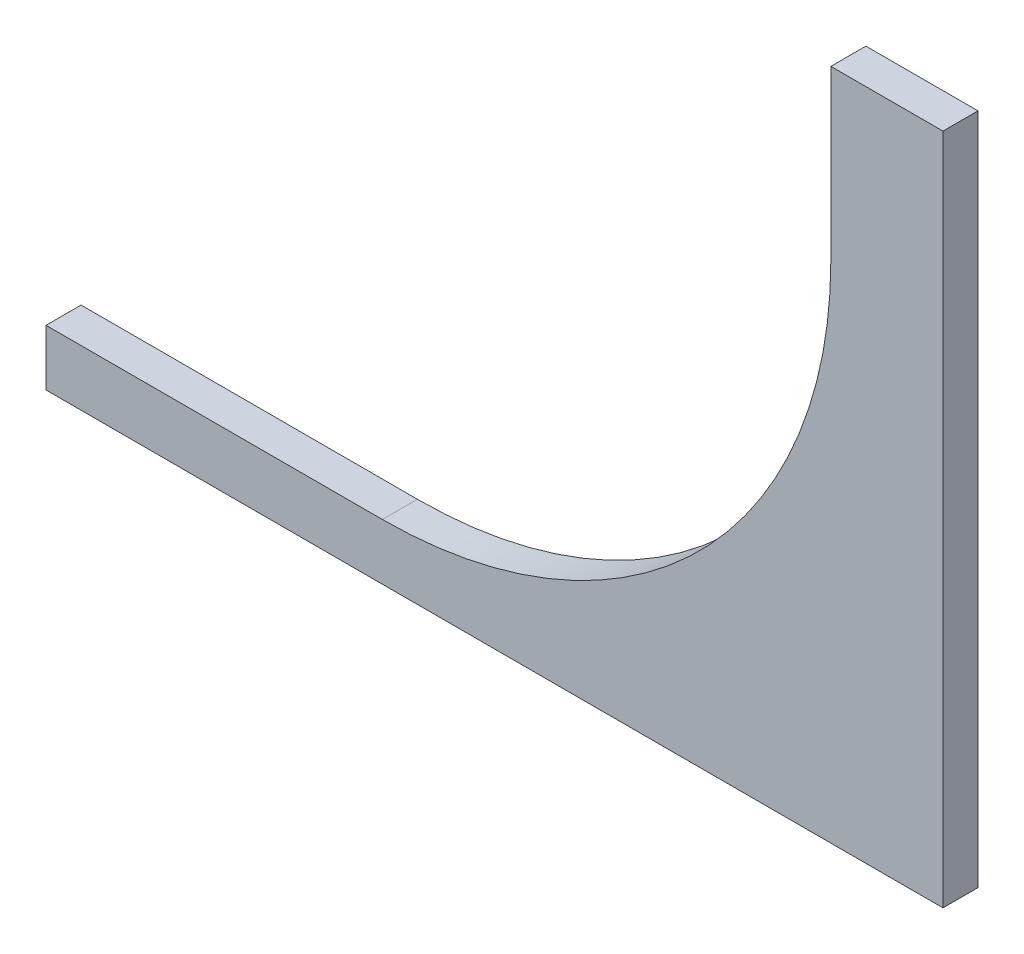
from build123d import *

# Parameters (mm, degrees)
SKETCH1_W           = 406.4
SKETCH1_H           = 304.8
BOSS_EXTRUDE1_DEPTH = 15.875
SKETCH2_R           = 9.525
CUT_EXTRUDE1_DEPTH  = 16.875
CUT_EXTRUDE2_DEPTH  = 16.875


with BuildPart() as part:
    # Sketch1 → Boss-Extrude1 (new body)
    with BuildSketch(Plane.XY):
        with Locations((203.2, 152.4)):
            Rectangle(SKETCH1_W, SKETCH1_H)
    extrude(amount=BOSS_EXTRUDE1_DEPTH)

    # Sketch2 → Cut-Extrude1 (cut, through all)
    with BuildSketch(Plane.XY.offset(15.875)):
        with Locations((152.4, 228.6)):
            Circle(SKETCH2_R)
    extrude(amount=-CUT_EXTRUDE1_DEPTH, mode=Mode.SUBTRACT)

    # Sketch3 → Cut-Extrude2 (cut, through all)
    with BuildSketch(Plane.XY.offset(15.875)):
        with BuildLine():
            Line((152.4, 25.4), (0, 25.4))
            Line((0, 25.4), (0, 304.8))
            Line((0, 304.8), (355.6, 304.8))
            Line((355.6, 304.8), (355.6, 228.6))
            ThreePointArc((355.6, 228.6), (296.084097937, 84.915902063), (152.4, 25.4))
        make_face()
    extrude(amount=-CUT_EXTRUDE2_DEPTH, mode=Mode.SUBTRACT)


solid = part.part
